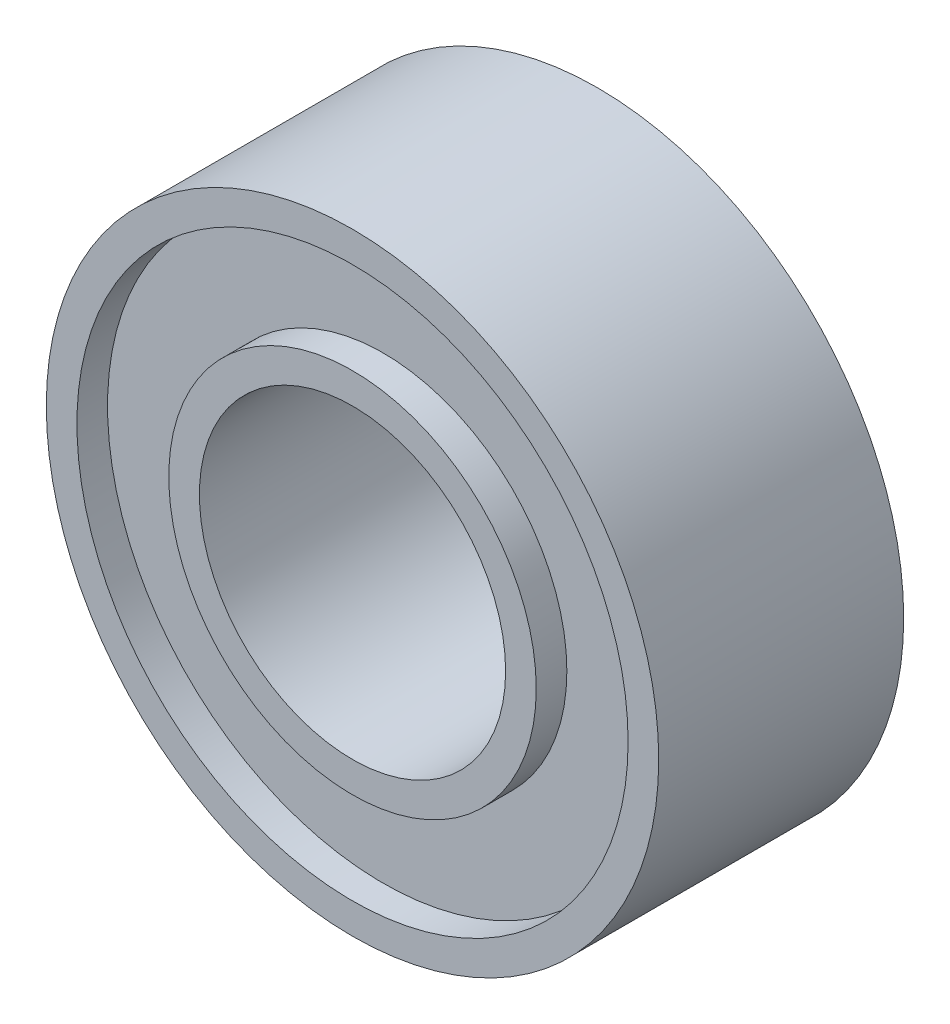
from build123d import *

# Parameters (mm, degrees)
SKETCH_2_R          = 5
SKETCH_2_R_2        = 2.5
EXTRUDE_1_DEPTH     = 4
SKETCH_3_R          = 4.5
SKETCH_3_R_2        = 3
CUT_EXTRUDE_1_DEPTH = 0.5
CUT_EXTRUDE_START   = -4
SKETCH_3_2_R        = 4.5
SKETCH_3_2_R_2      = 3
CUT_EXTRUDE_2_DEPTH = 0.5


with BuildPart() as part:
    # 草图2 → 凸台-拉伸1 (new body)
    with BuildSketch(Plane.XY):
        Circle(SKETCH_2_R)
        Circle(SKETCH_2_R_2, mode=Mode.SUBTRACT)
    extrude(amount=EXTRUDE_1_DEPTH)

    # 草图3 → 切除-拉伸1 (cut)
    with BuildSketch(Plane.XY.offset(4)):
        Circle(SKETCH_3_R)
        Circle(SKETCH_3_R_2, mode=Mode.SUBTRACT)
    extrude(amount=-CUT_EXTRUDE_1_DEPTH, mode=Mode.SUBTRACT)

    # 草图3<2> → 切除-拉伸2 (cut)
    with BuildSketch(Plane.XY.offset(4).offset(CUT_EXTRUDE_START)):
        Circle(SKETCH_3_2_R)
        Circle(SKETCH_3_2_R_2, mode=Mode.SUBTRACT)
    extrude(amount=CUT_EXTRUDE_2_DEPTH, mode=Mode.SUBTRACT)


solid = part.part
